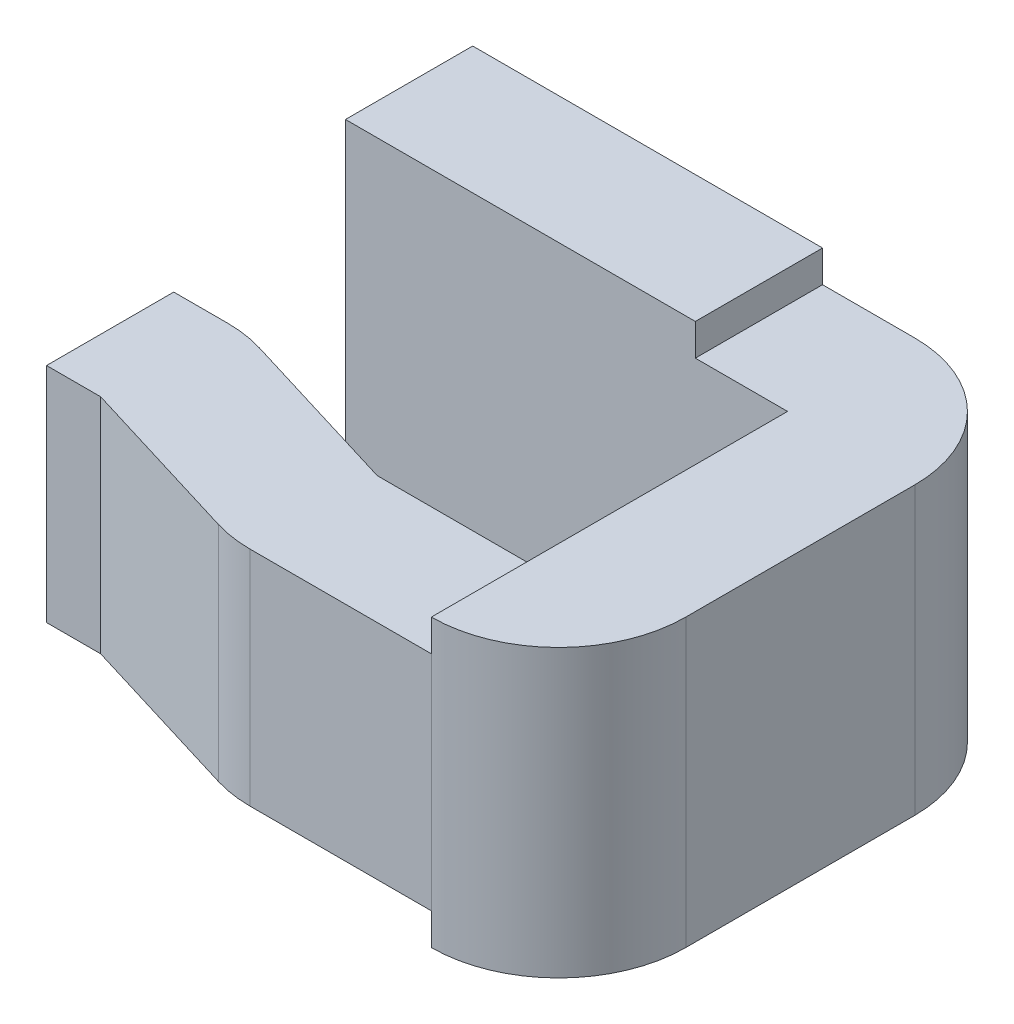
from build123d import *

# Parameters (mm, degrees)
BOSS_EXTRUDE1_DEPTH = 0.55
SKETCH4_W           = 1.309613551
SKETCH4_H           = 0.1
CUT_EXTRUDE1_DEPTH  = 3.411845766
SKETCH5_W           = 1.39
SKETCH5_H           = 0.983113088
CUT_EXTRUDE2_DEPTH  = 3.095280411


with BuildPart() as part:
    # Sketch1 → Boss-Extrude1 (new, symmetric)
    with BuildSketch(Plane(origin=(0, 0, 0), x_dir=(1, 0, 0), z_dir=(0, 1, 0))):
        with BuildLine():
            Line((0, -0.2), (1.39, -0.2))
            Line((1.39, -0.2), (1.39, -0.92))
            Line((1.39, -0.92), (0.819829801, -0.92))
            Line((0.819829801, -0.92), (0.286892857, -0.757409068))
            ThreePointArc((0.286892857, -0.757409068), (0.229177094, -0.744376206), (0.170170199, -0.74))
            Line((0.170170199, -0.74), (0, -0.74))
            Line((0, -0.74), (0, -1.14))
            Line((0, -1.14), (0.170170199, -1.14))
            Line((0.170170199, -1.14), (0.703107143, -1.302590932))
            ThreePointArc((0.703107143, -1.302590932), (0.760822906, -1.315623794), (0.819829801, -1.32))
            Line((0.819829801, -1.32), (1.39, -1.32))
            ThreePointArc((1.39, -1.32), (1.672842712, -1.202842712), (1.79, -0.92))
            Line((1.79, -0.92), (1.79, -0.2))
            ThreePointArc((1.79, -0.2), (1.672842712, 0.082842712), (1.39, 0.2))
            Line((1.39, 0.2), (0, 0.2))
            Line((0, 0.2), (0, -0.2))
        make_face()
    extrude(amount=BOSS_EXTRUDE1_DEPTH, both=True)

    # Sketch4 → Cut-Extrude1 (cut, through all)
    with BuildSketch(Plane(origin=(0, 0, -0.2), x_dir=(-1, 0, 0), z_dir=(0, 0, -1))):
        with Locations((-1.754806776, 0.5)):
            Rectangle(SKETCH4_W, SKETCH4_H)
    cut_extrude1 = extrude(amount=-CUT_EXTRUDE1_DEPTH, mode=Mode.SUBTRACT)

    # Mirror1: Cut-Extrude1 across plane
    add(cut_extrude1.mirror(Plane.ZX), mode=Mode.SUBTRACT)

    # Sketch5 → Cut-Extrude2 (cut, through all)
    with BuildSketch(Plane(origin=(0, 0, 0.74), x_dir=(-1, 0, 0), z_dir=(0, 0, -1))):
        with Locations((-0.695, 0.841556544)):
            Rectangle(SKETCH5_W, SKETCH5_H)
    cut_extrude2 = extrude(amount=-CUT_EXTRUDE2_DEPTH, mode=Mode.SUBTRACT)

    # Mirror2: Cut-Extrude2 across plane
    add(cut_extrude2.mirror(Plane.ZX), mode=Mode.SUBTRACT)


solid = part.part
